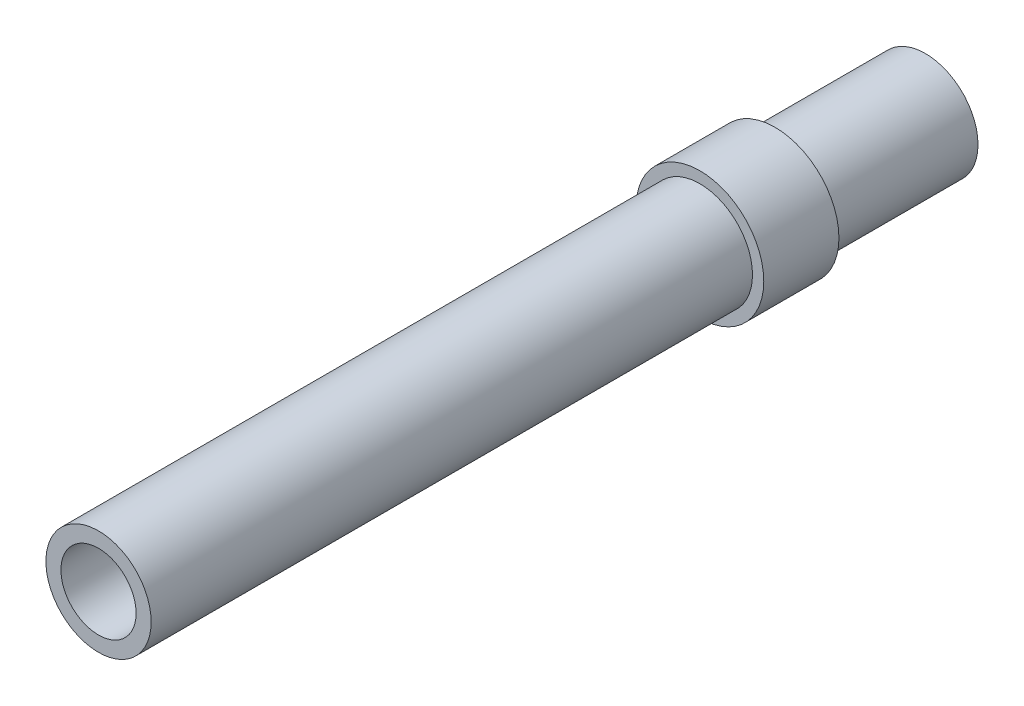
from build123d import *

# Parameters (mm, degrees)
IZIM1_R                     = 3.5
IZIM1_R_2                   = 2.5
Y_KSEKLIK_EKSTR_ZYON1_DEPTH = 50
IZIM2_R                     = 3.5
Y_KSEKLIK_EKSTR_ZYON2_DEPTH = 5
IZIM3_R                     = 4.25
Y_KSEKLIK_EKSTR_ZYON3_DEPTH = 5
IZIM5_R                     = 2.5
KES_EKSTR_ZYON1_DEPTH       = 60


with BuildPart() as part:
    # Çizim1 → Yükseklik-Ekstrüzyon1 (new body)
    with BuildSketch(Plane.XY):
        Circle(IZIM1_R)
        Circle(IZIM1_R_2, mode=Mode.SUBTRACT)
    extrude(amount=Y_KSEKLIK_EKSTR_ZYON1_DEPTH)

    # Çizim2 → Yükseklik-Ekstrüzyon2 (add)
    with BuildSketch(Plane.XY.offset(50)):
        Circle(IZIM2_R)
    extrude(amount=Y_KSEKLIK_EKSTR_ZYON2_DEPTH)

    # Çizim3 → Yükseklik-Ekstrüzyon3 (add)
    with BuildSketch(Plane.XY.offset(10)):
        Circle(IZIM3_R)
    extrude(amount=Y_KSEKLIK_EKSTR_ZYON3_DEPTH)

    # Çizim5 → Kes-Ekstrüzyon1 (cut)
    with BuildSketch(Plane(origin=(0, 0, 10), x_dir=(-1, 0, 0), z_dir=(0, 0, -1))):
        with Locations(Location((0, 0, 0), (0, 0, 180))):
            Circle(IZIM5_R)
    extrude(amount=-KES_EKSTR_ZYON1_DEPTH, mode=Mode.SUBTRACT)


solid = part.part
